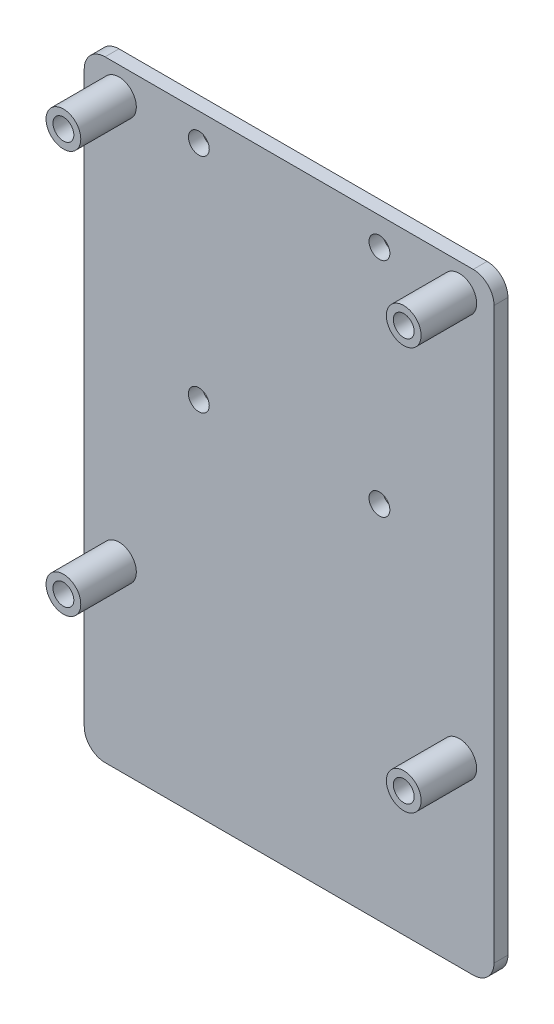
from build123d import *

# Parameters (mm, degrees)
SKETCH1_W           = 59
SKETCH1_H           = 88
SKETCH1_R           = 1.5
SKETCH1_R_2         = 2.5
BOSS_EXTRUDE1_DEPTH = 2
SKETCH1_3_R         = 2.5
SKETCH1_3_R_2       = 1.5
BOSS_EXTRUDE2_DEPTH = 10
FILLET1_R           = 3


with BuildPart() as part:
    # Sketch1 → Boss-Extrude1 (new body)
    with BuildSketch(Plane.XY):
        with Locations((0, -24)):
            Rectangle(SKETCH1_W, SKETCH1_H)
        with Locations((13, 16)):
            Circle(SKETCH1_R, mode=Mode.SUBTRACT)
        with Locations((13, -16)):
            Circle(SKETCH1_R, mode=Mode.SUBTRACT)
        with Locations((-13, -16)):
            Circle(SKETCH1_R, mode=Mode.SUBTRACT)
        with Locations((-13, 16)):
            Circle(SKETCH1_R, mode=Mode.SUBTRACT)
        with Locations((-24.5, 16)):
            Circle(SKETCH1_R_2, mode=Mode.SUBTRACT)
        with Locations((-24.5, -42)):
            Circle(SKETCH1_R_2, mode=Mode.SUBTRACT)
        with Locations((24.5, -42)):
            Circle(SKETCH1_R_2, mode=Mode.SUBTRACT)
        with Locations((24.5, 16)):
            Circle(SKETCH1_R_2, mode=Mode.SUBTRACT)
    extrude(amount=BOSS_EXTRUDE1_DEPTH)

    # Sketch1_3 → Boss-Extrude2 (add)
    # profile 1 of 4: a face of its own
    with BuildSketch(Plane.XY):
        with Locations((-24.5, 16)):
            Circle(SKETCH1_3_R)
        with Locations((-24.5, 16)):
            Circle(SKETCH1_3_R_2, mode=Mode.SUBTRACT)
    # profile 2 of 4: a face of its own
    with BuildSketch(Plane.XY):
        with Locations((24.5, 16)):
            Circle(SKETCH1_3_R)
        with Locations((24.5, 16)):
            Circle(SKETCH1_3_R_2, mode=Mode.SUBTRACT)
    # profile 3 of 4: a face of its own
    with BuildSketch(Plane.XY):
        with Locations((-24.5, -42)):
            Circle(SKETCH1_3_R)
        with Locations((-24.5, -42)):
            Circle(SKETCH1_3_R_2, mode=Mode.SUBTRACT)
    # profile 4 of 4: a face of its own
    with BuildSketch(Plane.XY):
        with Locations((24.5, -42)):
            Circle(SKETCH1_3_R)
        with Locations((24.5, -42)):
            Circle(SKETCH1_3_R_2, mode=Mode.SUBTRACT)
    extrude(amount=BOSS_EXTRUDE2_DEPTH)

    # Fillet1
    fillet1_edges = [part.edges().sort_by_distance(p)[0] for p in [
        (29.5, 20, 1),
        (-29.5, 20, 1),
        (29.5, -68, 1),
        (-29.5, -68, 1),
    ]]
    fillet(fillet1_edges, radius=FILLET1_R)


solid = part.part
